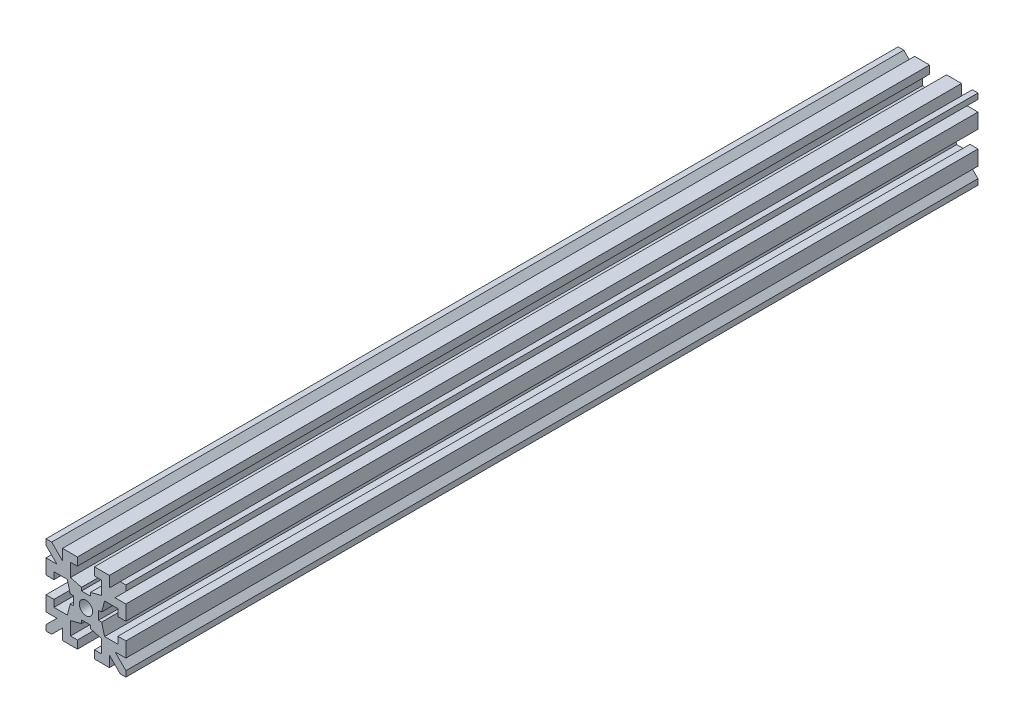
from build123d import *

# Parameters (mm, degrees)
RESSALTO_EXTRUS_O1_DEPTH   = 80
ESPELHAR2_COPY_1_DEPTH     = 80
ESBO_O2_R                  = 1.25
CORTE_EXTRUS_O1_DEPTH      = 1
CORTE_EXTRUS_O1_DEPTH_BACK = 161


with BuildPart() as part:
    # Esboço1 → Ressalto-extrusão1 (new body, symmetric)
    with BuildSketch(Plane.XY):
        Polygon((0, 2.35), (-0.825, 2.35), (-0.825, 2.95), (-2.9, 3.5), (-2.9, 6), (-1.6, 6), (-1.6, 7.5), (-4.4, 7.5), (-4.4, 5.460660172), (-6.439339828, 7.5), (-7.5, 7.5), (-7.5, 6.439339828), (-5.460660172, 4.4), (-7.5, 4.4), (-7.5, 1.6), (-6, 1.6), (-6, 2.9), (-3.5, 2.9), (-2.95, 0.825), (-2.35, 0.825), (-2.35, 0), (0, 0), align=None)
    ressalto_extrus_o1 = extrude(amount=RESSALTO_EXTRUS_O1_DEPTH, both=True)

    # Espelhar1: Ressalto-extrusão1 across plane
    add(ressalto_extrus_o1.mirror(Plane.ZX))

    # Espelhar2: Ressalto-extrusão1 across plane
    add(ressalto_extrus_o1.mirror(Plane(origin=(0, 0, 0), x_dir=(0, 0, 1), z_dir=(1, 0, 0))))

    # Espelhar2 copy 1 sketch → Espelhar2 copy 1 (add, symmetric)
    with BuildSketch(Plane(origin=(0, 0, 0), x_dir=(-1, 0, 0), z_dir=(0, 0, 1))):
        Polygon((0, 2.35), (-0.825, 2.35), (-0.825, 2.95), (-2.9, 3.5), (-2.9, 6), (-1.6, 6), (-1.6, 7.5), (-4.4, 7.5), (-4.4, 5.460660172), (-6.439339828, 7.5), (-7.5, 7.5), (-7.5, 6.439339828), (-5.460660172, 4.4), (-7.5, 4.4), (-7.5, 1.6), (-6, 1.6), (-6, 2.9), (-3.5, 2.9), (-2.95, 0.825), (-2.35, 0.825), (-2.35, 0), (0, 0), align=None)
    extrude(amount=ESPELHAR2_COPY_1_DEPTH, both=True)

    # Esboço2 → Corte-extrusão1 (cut, two sides)
    with BuildSketch(Plane.XY.offset(80)) as corte_extrus_o1_sk:
        Circle(ESBO_O2_R)
    extrude(amount=CORTE_EXTRUS_O1_DEPTH, mode=Mode.SUBTRACT)
    extrude(corte_extrus_o1_sk.sketch, amount=-CORTE_EXTRUS_O1_DEPTH_BACK, mode=Mode.SUBTRACT)


solid = part.part
